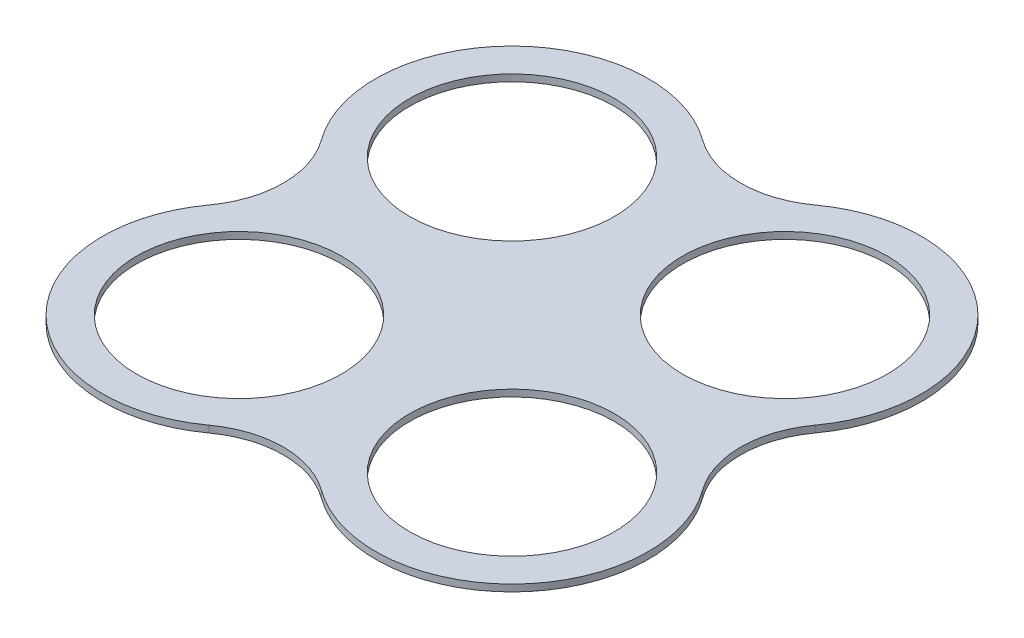
from build123d import *

# Parameters (mm, degrees)
SKETCH1_R           = 95.25
BOSS_EXTRUDE1_DEPTH = 6.35


with BuildPart() as part:
    # Sketch1 → Boss-Extrude1 (new body)
    with BuildSketch(Plane(origin=(0, 0, 0), x_dir=(1, 0, 0), z_dir=(0, 1, 0))):
        with BuildLine():
            ThreePointArc((74.705882353, 102.703608222), (-89.802561211, 89.802561211), (-102.703608222, -74.705882353))
            ThreePointArc((-102.703608222, -74.705882353), (-85.696133978, -127), (-102.703608222, -179.294117647))
            ThreePointArc((-102.703608222, -179.294117647), (-89.802561211, -343.802561211), (74.705882353, -356.703608222))
            ThreePointArc((74.705882353, -356.703608222), (127, -339.696133978), (179.294117647, -356.703608222))
            ThreePointArc((179.294117647, -356.703608222), (343.802561211, -343.802561211), (356.703608222, -179.294117647))
            ThreePointArc((356.703608222, -179.294117647), (339.696133978, -127), (356.703608222, -74.705882353))
            ThreePointArc((356.703608222, -74.705882353), (343.802561211, 89.802561211), (179.294117647, 102.703608222))
            ThreePointArc((179.294117647, 102.703608222), (127, 85.696133978), (74.705882353, 102.703608222))
        make_face()
        Circle(SKETCH1_R, mode=Mode.SUBTRACT)
        with Locations((254, 0)):
            Circle(SKETCH1_R, mode=Mode.SUBTRACT)
        with Locations((254, -254)):
            Circle(SKETCH1_R, mode=Mode.SUBTRACT)
        with Locations((0, -254)):
            Circle(SKETCH1_R, mode=Mode.SUBTRACT)
    extrude(amount=BOSS_EXTRUDE1_DEPTH)


solid = part.part
